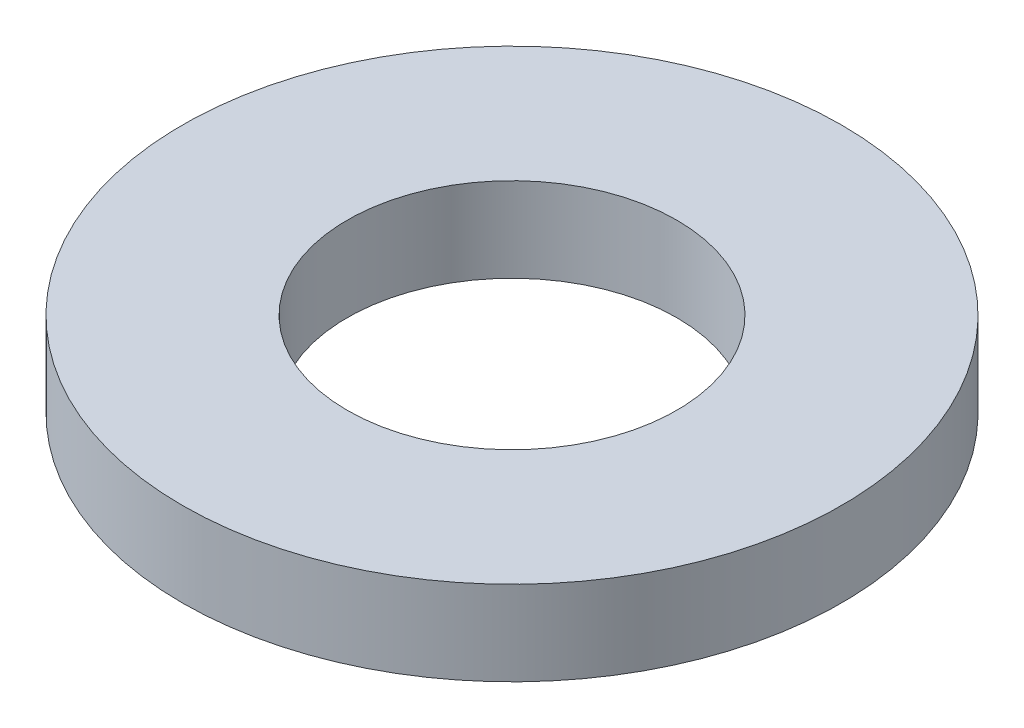
from build123d import *

# Parameters (mm, degrees)
SKETCH_1_W = 1.9812
SKETCH_1_H = 1.016


with BuildPart() as part:
    # 草图1 → 旋转1 (revolve)
    with BuildSketch(Plane.XY):
        with Locations((2.9718, 0.508)):
            Rectangle(SKETCH_1_W, SKETCH_1_H)
    revolve(axis=Axis((0, 1.016, 0), (0, -1, 0)))


solid = part.part
